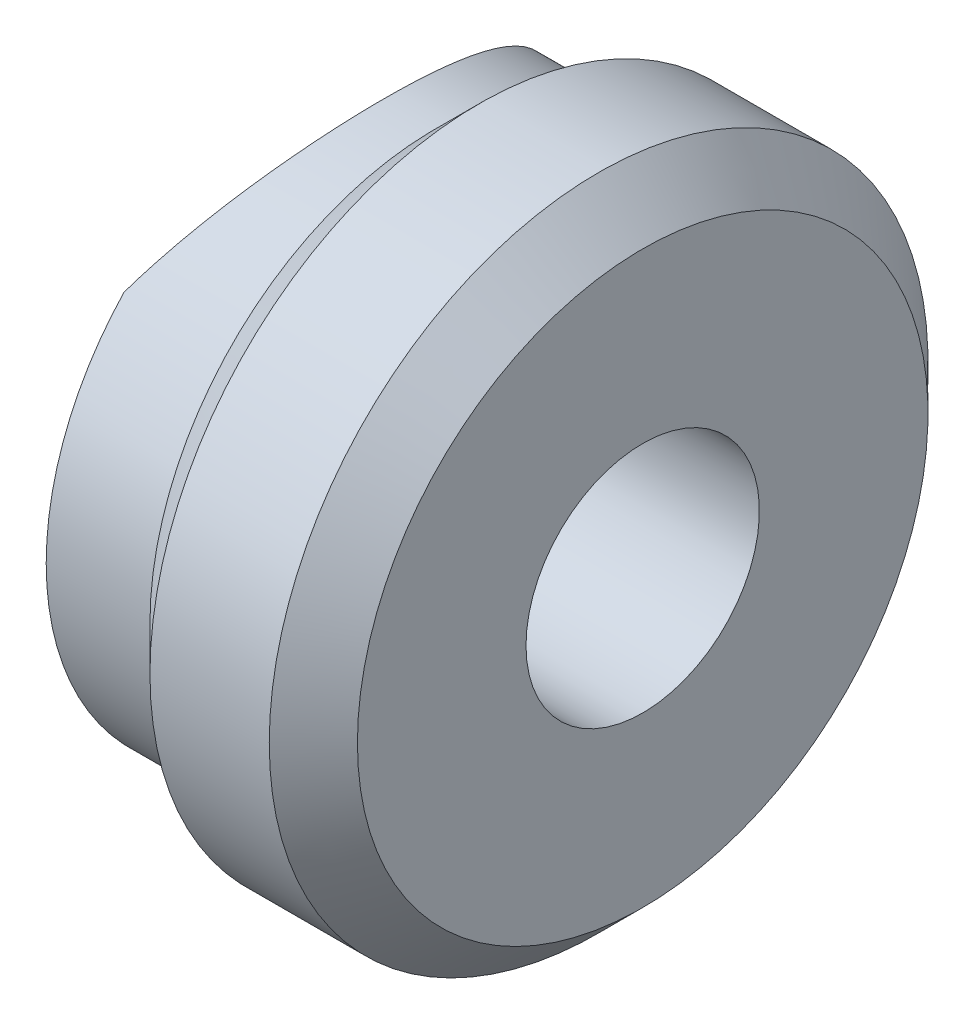
from build123d import *

# Parameters (mm, degrees)
ESBO_O2_R                  = 8.5
CORTE_EXTRUS_O1_DEPTH      = 7.35
CORTE_EXTRUS_O1_DEPTH_BACK = 7.35


with BuildPart() as part:
    # Esboço1 → Revolução1 (revolve)
    with BuildSketch(Plane.XY):
        Polygon((0, 5.5), (2, 5.5), (2.85, 6.35), (5.15, 6.35), (6, 5.5), (6, 2.25), (0.692820323, 2.25), (0, 2.65), align=None)
    revolve(axis=Axis((14.266397253, 0, 0), (1, 0, 0)))

    # Esboço2 → Corte-extrusão1 (cut, two sides)
    with BuildSketch(Plane(origin=(0, 0, 0), x_dir=(1, 0, 0), z_dir=(0, 1, 0))) as corte_extrus_o1_sk:
        with Locations((-7.5, 0)):
            Circle(ESBO_O2_R)
    extrude(amount=CORTE_EXTRUS_O1_DEPTH, mode=Mode.SUBTRACT)
    extrude(corte_extrus_o1_sk.sketch, amount=-CORTE_EXTRUS_O1_DEPTH_BACK, mode=Mode.SUBTRACT)


solid = part.part
